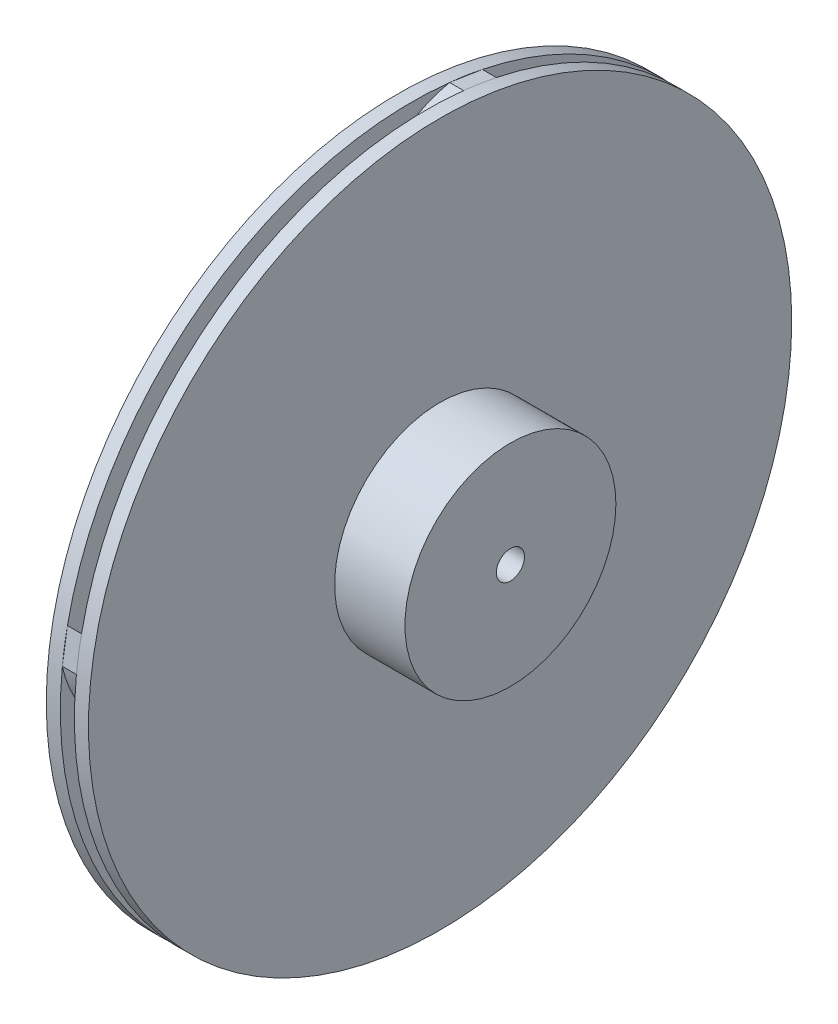
from build123d import *

# Parameters (mm, degrees)
BOSS_EXTRUDE1_DEPTH   = 1
BOSS_EXTRUDE1_2_DEPTH = 1
BOSS_EXTRUDE1_3_DEPTH = 1
BOSS_EXTRUDE1_4_DEPTH = 1
SKETCH2_R             = 25
SKETCH2_R_2           = 5
BOSS_EXTRUDE2_DEPTH   = 1
BOSS_EXTRUDE6_START   = -1
SKETCH2_4_R           = 25
SKETCH2_4_R_2         = 5
BOSS_EXTRUDE6_DEPTH   = 1
SKETCH3_R             = 7.5
BOSS_EXTRUDE7_DEPTH   = 5
SKETCH4_R             = 1
CUT_EXTRUDE1_DEPTH    = 4


with BuildPart() as part:
    # Sketch1 → Boss-Extrude1 (new body)
    with BuildSketch(Plane(origin=(0, 0, 0), x_dir=(0, 0, -1), z_dir=(1, 0, 0))):
        with BuildLine():
            add(Edge.make_bspline(
                [(0, 5), (4.497529661, 10.734535644), (18.077265621, 8.404390401), (22.903151971, -1.371454076), (24.494897428, -5)],
                knots=[0, 0, 0, 0, 0.618777628, 1, 1, 1, 1], degree=3))
            add(Edge.make_bspline(
                [(24.494897428, -5), (24.856687291, -2.673031407)],
                knots=[0, 0, 1, 1], degree=1))
            add(Edge.make_bspline(
                [(-1.492986361, 4.77189603), (-1.334435901, 6.923416971), (1.516351493, 9.375782971), (6.922460383, 11.063211687), (12.668210337, 10.322852941), (18.630485351, 7.165584221), (22.391904574, 2.350944019), (24.550618301, -1.104983558), (24.856687291, -2.673031407)],
                knots=[0, 0, 0, 0, 0.172506063, 0.296264897, 0.482616547, 0.652804407, 0.864378799, 1, 1, 1, 1], degree=3))
            add(Edge.make_bspline(
                [(-1.492986361, 4.77189603), (0, 5)],
                knots=[0, 0, 1, 1], degree=1))
        make_face()
    extrude(amount=BOSS_EXTRUDE1_DEPTH)



with BuildPart() as body_2:
    # Sketch1 → Boss-Extrude1 2 (new body)
    with BuildSketch(Plane(origin=(0, 0, 0), x_dir=(0, 0, -1), z_dir=(1, 0, 0))):
        with BuildLine():
            add(Edge.make_bspline(
                [(4.77189603, 1.492986361), (6.923416971, 1.334435901), (9.375782971, -1.516351493), (11.063211687, -6.922460383), (10.322852941, -12.668210337), (7.165584221, -18.630485351), (2.350944019, -22.391904574), (-1.104983558, -24.550618301), (-2.673031407, -24.856687291)],
                knots=[0, 0, 0, 0, 0.172506063, 0.296264897, 0.482616547, 0.652804407, 0.864378799, 1, 1, 1, 1], degree=3))
            add(Edge.make_bspline(
                [(-5, -24.494897428), (-2.673031407, -24.856687291)],
                knots=[0, 0, 1, 1], degree=1))
            add(Edge.make_bspline(
                [(5, 0), (10.734535644, -4.497529661), (8.404390401, -18.077265621), (-1.371454076, -22.903151971), (-5, -24.494897428)],
                knots=[0, 0, 0, 0, 0.618777628, 1, 1, 1, 1], degree=3))
            add(Edge.make_bspline(
                [(4.77189603, 1.492986361), (5, 0)],
                knots=[0, 0, 1, 1], degree=1))
        make_face()
    extrude(amount=BOSS_EXTRUDE1_2_DEPTH)


with BuildPart() as body_3:
    # Sketch1 → Boss-Extrude1 3 (new body)
    with BuildSketch(Plane(origin=(0, 0, 0), x_dir=(0, 0, -1), z_dir=(1, 0, 0))):
        with BuildLine():
            add(Edge.make_bspline(
                [(1.492986361, -4.77189603), (1.334435901, -6.923416971), (-1.516351493, -9.375782971), (-6.922460383, -11.063211687), (-12.668210337, -10.322852941), (-18.630485351, -7.165584221), (-22.391904574, -2.350944019), (-24.550618301, 1.104983558), (-24.856687291, 2.673031407)],
                knots=[0, 0, 0, 0, 0.172506063, 0.296264897, 0.482616547, 0.652804407, 0.864378799, 1, 1, 1, 1], degree=3))
            add(Edge.make_bspline(
                [(-24.494897428, 5), (-24.856687291, 2.673031407)],
                knots=[0, 0, 1, 1], degree=1))
            add(Edge.make_bspline(
                [(0, -5), (-4.497529661, -10.734535644), (-18.077265621, -8.404390401), (-22.903151971, 1.371454076), (-24.494897428, 5)],
                knots=[0, 0, 0, 0, 0.618777628, 1, 1, 1, 1], degree=3))
            add(Edge.make_bspline(
                [(1.492986361, -4.77189603), (0, -5)],
                knots=[0, 0, 1, 1], degree=1))
        make_face()
    extrude(amount=BOSS_EXTRUDE1_3_DEPTH)


with BuildPart() as body_4:
    # Sketch1 → Boss-Extrude1 4 (new body)
    with BuildSketch(Plane(origin=(0, 0, 0), x_dir=(0, 0, -1), z_dir=(1, 0, 0))):
        with BuildLine():
            add(Edge.make_bspline(
                [(-4.77189603, -1.492986361), (-6.923416971, -1.334435901), (-9.375782971, 1.516351493), (-11.063211687, 6.922460383), (-10.322852941, 12.668210337), (-7.165584221, 18.630485351), (-2.350944019, 22.391904574), (1.104983558, 24.550618301), (2.673031407, 24.856687291)],
                knots=[0, 0, 0, 0, 0.172506063, 0.296264897, 0.482616547, 0.652804407, 0.864378799, 1, 1, 1, 1], degree=3))
            add(Edge.make_bspline(
                [(5, 24.494897428), (2.673031407, 24.856687291)],
                knots=[0, 0, 1, 1], degree=1))
            add(Edge.make_bspline(
                [(-5, 0), (-10.734535644, 4.497529661), (-8.404390401, 18.077265621), (1.371454076, 22.903151971), (5, 24.494897428)],
                knots=[0, 0, 0, 0, 0.618777628, 1, 1, 1, 1], degree=3))
            add(Edge.make_bspline(
                [(-4.77189603, -1.492986361), (-5, 0)],
                knots=[0, 0, 1, 1], degree=1))
        make_face()
    extrude(amount=BOSS_EXTRUDE1_4_DEPTH)


with BuildPart() as part_1:
    add(part.part)

    add(body_2.part)  # Boss-Extrude2 merges body 2

    add(body_3.part)  # Boss-Extrude2 merges body 3

    add(body_4.part)  # Boss-Extrude2 merges body 4
    # Sketch2 → Boss-Extrude2 (add)
    with BuildSketch(Plane(origin=(1, 0, 0), x_dir=(0, 0, -1), z_dir=(1, 0, 0))):
        Circle(SKETCH2_R)
        Circle(SKETCH2_R_2, mode=Mode.SUBTRACT)
    extrude(amount=BOSS_EXTRUDE2_DEPTH)

    # Sketch2_4 → Boss-Extrude6 (add)
    with BuildSketch(Plane(origin=(1, 0, 0), x_dir=(0, 0, -1), z_dir=(1, 0, 0)).offset(BOSS_EXTRUDE6_START)):
        Circle(SKETCH2_4_R)
        Circle(SKETCH2_4_R_2, mode=Mode.SUBTRACT)
    extrude(amount=-BOSS_EXTRUDE6_DEPTH)

    # Sketch3 → Boss-Extrude7 (add)
    with BuildSketch(Plane(origin=(2, 0, 0), x_dir=(0, 0, -1), z_dir=(1, 0, 0))):
        Circle(SKETCH3_R)
    extrude(amount=BOSS_EXTRUDE7_DEPTH)

    # Sketch4 → Cut-Extrude1 (cut)
    with BuildSketch(Plane(origin=(7, 0, 0), x_dir=(0, 0, -1), z_dir=(1, 0, 0))):
        Circle(SKETCH4_R)
    extrude(amount=-CUT_EXTRUDE1_DEPTH, mode=Mode.SUBTRACT)


solid = part_1.part
